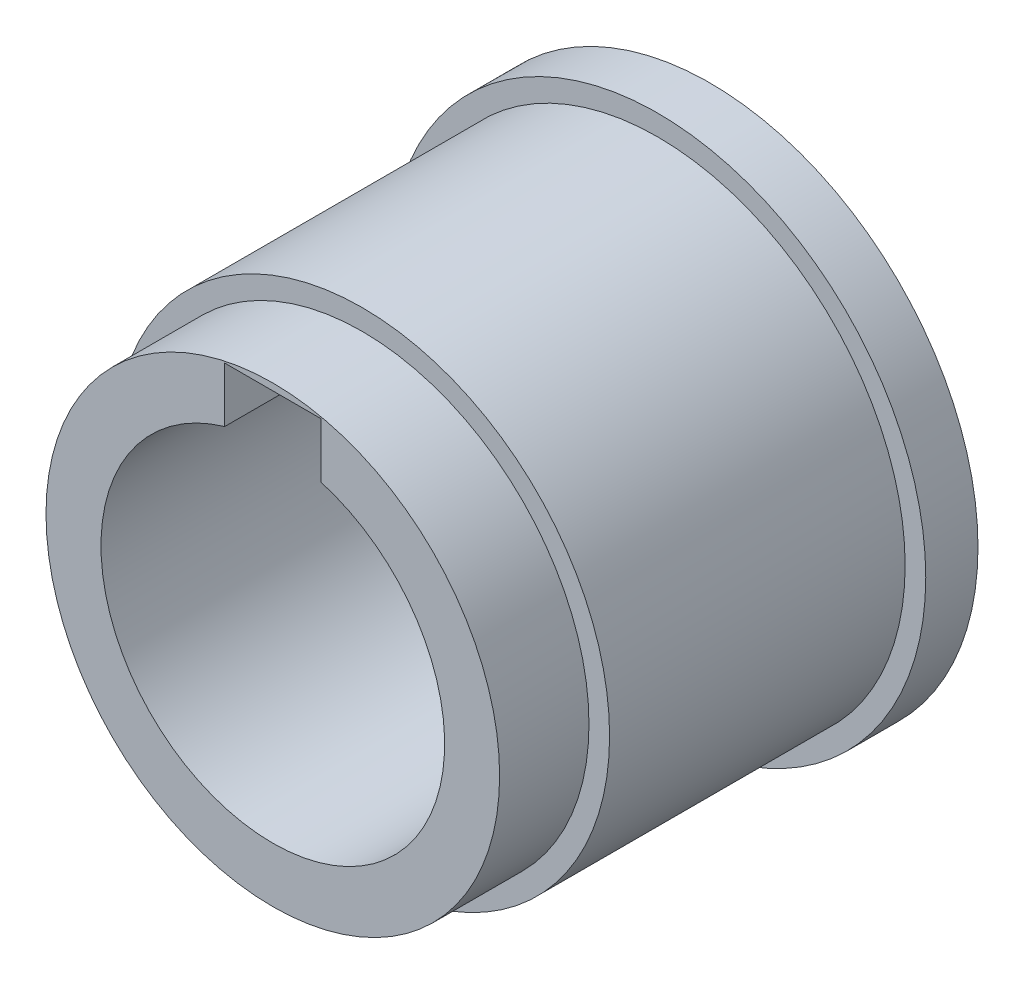
from build123d import *

# Parameters (mm, degrees)
SKETCH_2_W          = 7
SKETCH_2_H          = 7
CUT_EXTRUDE_1_DEPTH = 32.8


with BuildPart() as part:
    # Эскиз1 → Повернуть1 (revolve)
    with BuildSketch(Plane(origin=(0, 0, 0), x_dir=(0, 0, -1), z_dir=(1, 0, 0))):
        Polygon((26.8, 12.5), (-5, 12.5), (-5, 16.5), (1.5, 16.5), (1.5, 18), (23, 18), (23, 19.5), (26.8, 19.5), align=None)
    revolve(axis=Axis((0, 0, 1000), (0, 0, -1)))

    # Эскиз2 → Вырез-Вытянуть1 (cut, through all)
    with BuildSketch(Plane.XY.offset(5)):
        with Locations((0, 12.5)):
            Rectangle(SKETCH_2_W, SKETCH_2_H)
    extrude(amount=-CUT_EXTRUDE_1_DEPTH, mode=Mode.SUBTRACT)


solid = part.part
